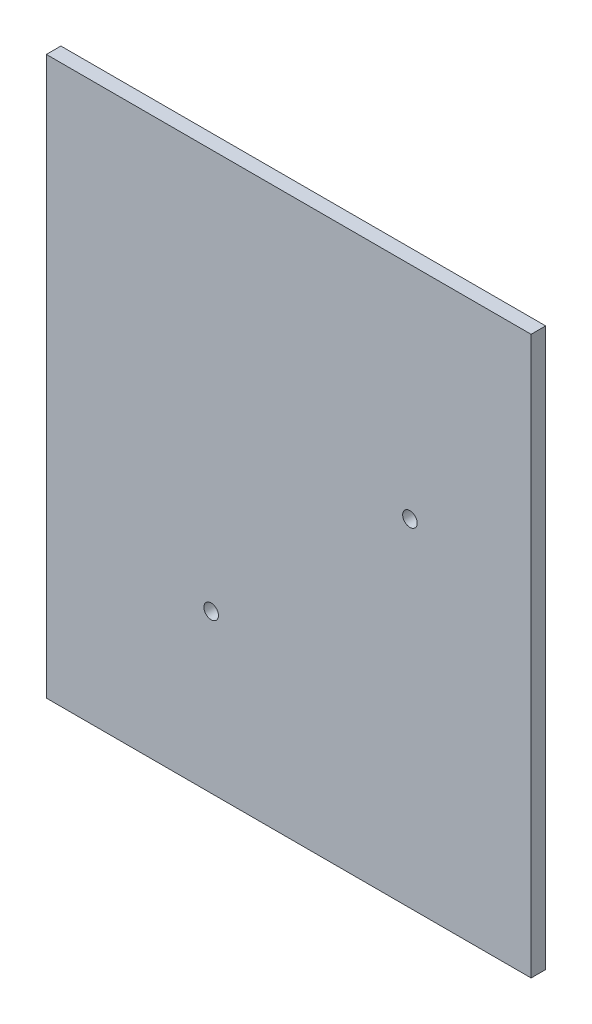
from build123d import *

# Parameters (mm, degrees)
ESQUISSE1_W             = 100
ESQUISSE1_H             = 115
BOSS_EXTRU_1_DEPTH      = 3
ESQUISSE2_R             = 1.5
ENL_V_MAT_EXTRU_1_DEPTH = 3


with BuildPart() as part:
    # Esquisse1 → Boss.-Extru.1 (new body)
    with BuildSketch(Plane.XY):
        Rectangle(ESQUISSE1_W, ESQUISSE1_H)
    extrude(amount=BOSS_EXTRU_1_DEPTH)

    # Esquisse2 → Enlèv. mat.-Extru.1 (cut)
    with BuildSketch(Plane.XY.offset(3)):
        with Locations((25, 12)):
            Circle(ESQUISSE2_R)
        with Locations((-16, -25)):
            Circle(ESQUISSE2_R)
    extrude(amount=-ENL_V_MAT_EXTRU_1_DEPTH, mode=Mode.SUBTRACT)


solid = part.part
